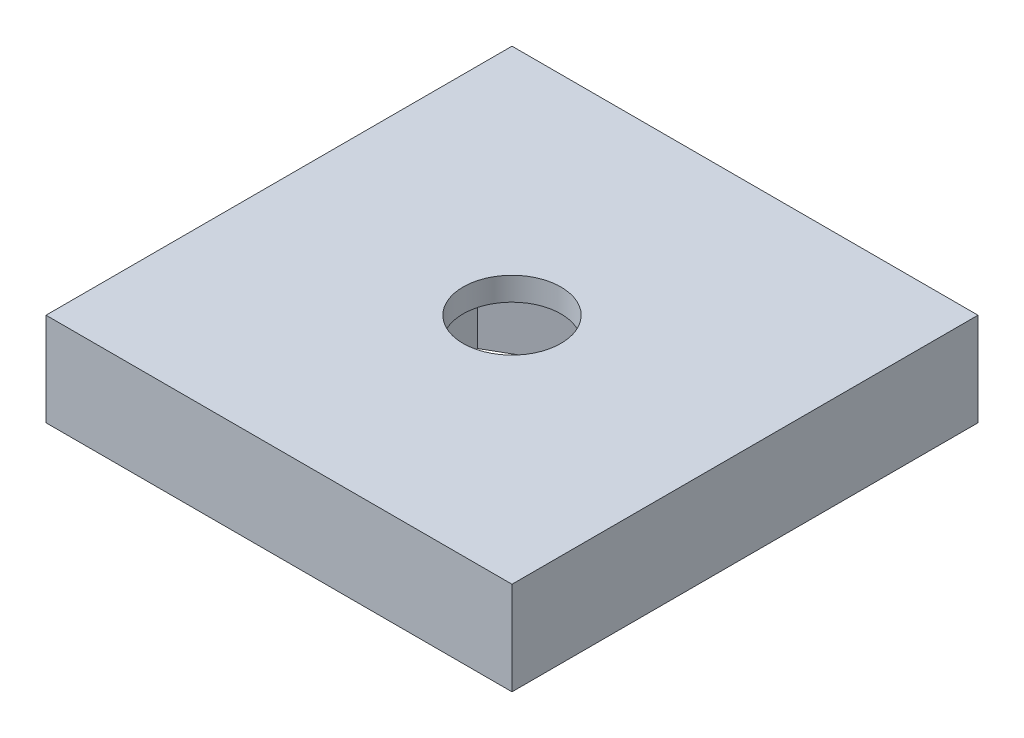
from build123d import *

# Parameters (mm, degrees)
SKETCH1_W               = 20
SKETCH1_H               = 20
BOSS_EXTRUDE1_DEPTH     = 4
CUT_EXTRUDE1_DEPTH      = 3
CUT_EXTRUDE2_DEPTH      = 15.696938457
CUT_EXTRUDE2_DEPTH_BACK = 15.696938457
SKETCH1_4_R             = 2.1


with BuildPart() as part:
    # Sketch1 → Boss-Extrude1 (new body)
    with BuildSketch(Plane(origin=(0, 0, 0), x_dir=(1, 0, 0), z_dir=(0, 1, 0))):
        Rectangle(SKETCH1_W, SKETCH1_H)
    extrude(amount=BOSS_EXTRUDE1_DEPTH)

    # Sketch1_3 → Cut-Extrude1 (cut)
    with BuildSketch(Plane(origin=(0, 0, 0), x_dir=(1, 0, 0), z_dir=(0, 1, 0))):
        Polygon((0, 4.041451884), (-3.5, 2.020725942), (-3.5, -2.020725942), (0, -4.041451884), (3.5, -2.020725942), (3.5, 2.020725942), align=None)
    extrude(amount=CUT_EXTRUDE1_DEPTH, mode=Mode.SUBTRACT)

    # Sketch1_4 → Cut-Extrude2 (cut, two sides: drawn at the far end of the back side and taken through both)
    with BuildSketch(Plane(origin=(0, 0, 0), x_dir=(1, 0, 0), z_dir=(0, 1, 0)).offset(-CUT_EXTRUDE2_DEPTH_BACK)):
        Circle(SKETCH1_4_R)
    extrude(amount=CUT_EXTRUDE2_DEPTH + CUT_EXTRUDE2_DEPTH_BACK, mode=Mode.SUBTRACT)


solid = part.part
